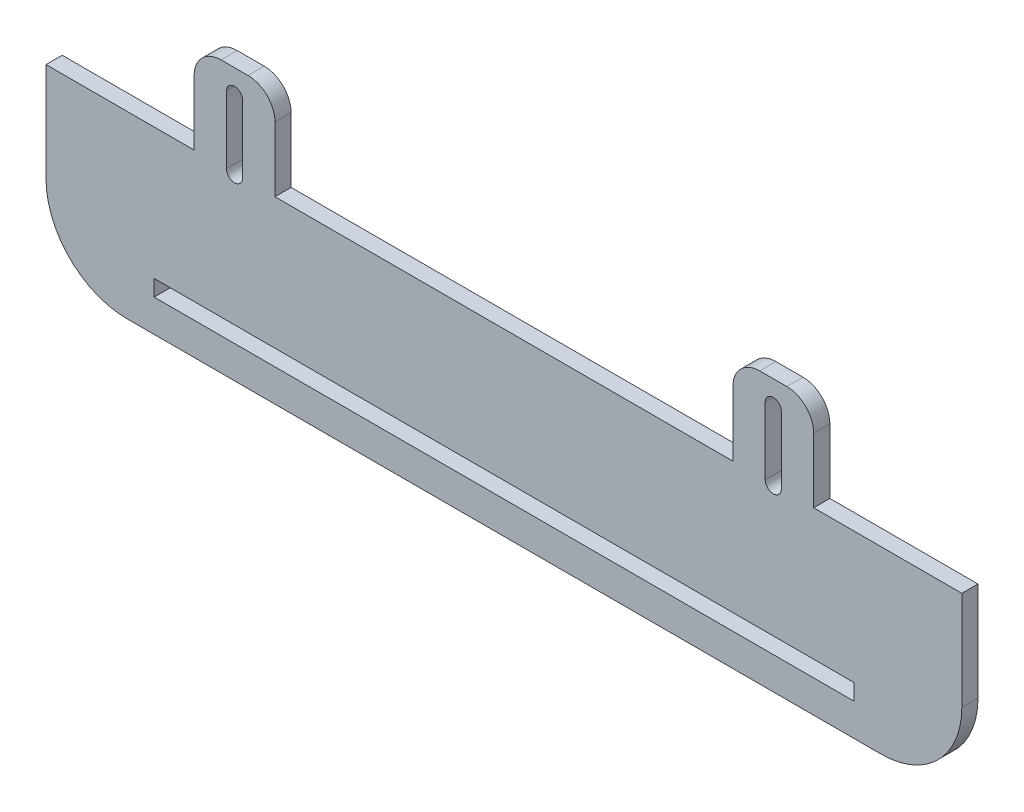
from build123d import *

# Parameters (mm, degrees)
BOSS_EXTRUDE1_DEPTH = 3
FILLET2_R           = 5
SKETCH2_W           = 129.874983815
SKETCH2_H           = 3
CUT_EXTRUDE1_DEPTH  = 10


with BuildPart() as part:
    # Sketch1 → Boss-Extrude1 (new body)
    with BuildSketch(Plane.XY):
        with BuildLine():
            Line((-88.622208542, -43.25), (-61.122208542, -43.25))
            Line((-61.122208542, -43.25), (-61.122208542, -26.25))
            Line((-61.122208542, -26.25), (-46.122208542, -26.25))
            Line((-46.122208542, -26.25), (-46.122208542, -43.25))
            Line((-46.122208542, -43.25), (38.877791458, -43.25))
            Line((38.877791458, -43.25), (38.877791458, -26.25))
            Line((38.877791458, -26.25), (53.877791458, -26.25))
            Line((53.877791458, -26.25), (53.877791458, -43.25))
            Line((53.877791458, -43.25), (81.377791458, -43.25))
            Line((81.377791458, -43.25), (81.377791458, -61.598486101))
            ThreePointArc((81.377791458, -61.598486101), (76.984393176, -72.205087819), (66.377791458, -76.598486101))
            Line((66.377791458, -76.598486101), (-73.622208542, -76.598486101))
            ThreePointArc((-73.622208542, -76.598486101), (-84.228810259, -72.205087819), (-88.622208542, -61.598486101))
            Line((-88.622208542, -61.598486101), (-88.622208542, -43.25))
        make_face()
        with BuildLine():
            Line((-55.122208542, -43.25), (-55.122208542, -30.75))
            ThreePointArc((-55.122208542, -30.75), (-53.622208542, -29.25), (-52.122208542, -30.75))
            Line((-52.122208542, -30.75), (-52.122208542, -43.25))
            ThreePointArc((-52.122208542, -43.25), (-53.622208542, -44.75), (-55.122208542, -43.25))
        make_face(mode=Mode.SUBTRACT)
        with BuildLine():
            Line((44.877791458, -43.25), (44.877791458, -30.75))
            ThreePointArc((44.877791458, -30.75), (46.377791458, -29.25), (47.877791458, -30.75))
            Line((47.877791458, -30.75), (47.877791458, -43.25))
            ThreePointArc((47.877791458, -43.25), (46.377791458, -44.75), (44.877791458, -43.25))
        make_face(mode=Mode.SUBTRACT)
    extrude(amount=BOSS_EXTRUDE1_DEPTH)

    # Fillet2
    fillet2_edges = [part.edges().sort_by_distance(p)[0] for p in [
        (-61.122208542, -26.25, 1.5),
        (-46.122208542, -26.25, 1.5),
        (38.877791458, -26.25, 1.5),
        (53.877791458, -26.25, 1.5),
    ]]
    fillet(fillet2_edges, radius=FILLET2_R)

    # Sketch2 → Cut-Extrude1 (cut)
    with BuildSketch(Plane.XY.offset(3)):
        with Locations((-3.622208542, -69.098486101)):
            Rectangle(SKETCH2_W, SKETCH2_H)
    extrude(amount=-CUT_EXTRUDE1_DEPTH, mode=Mode.SUBTRACT)


solid = part.part
